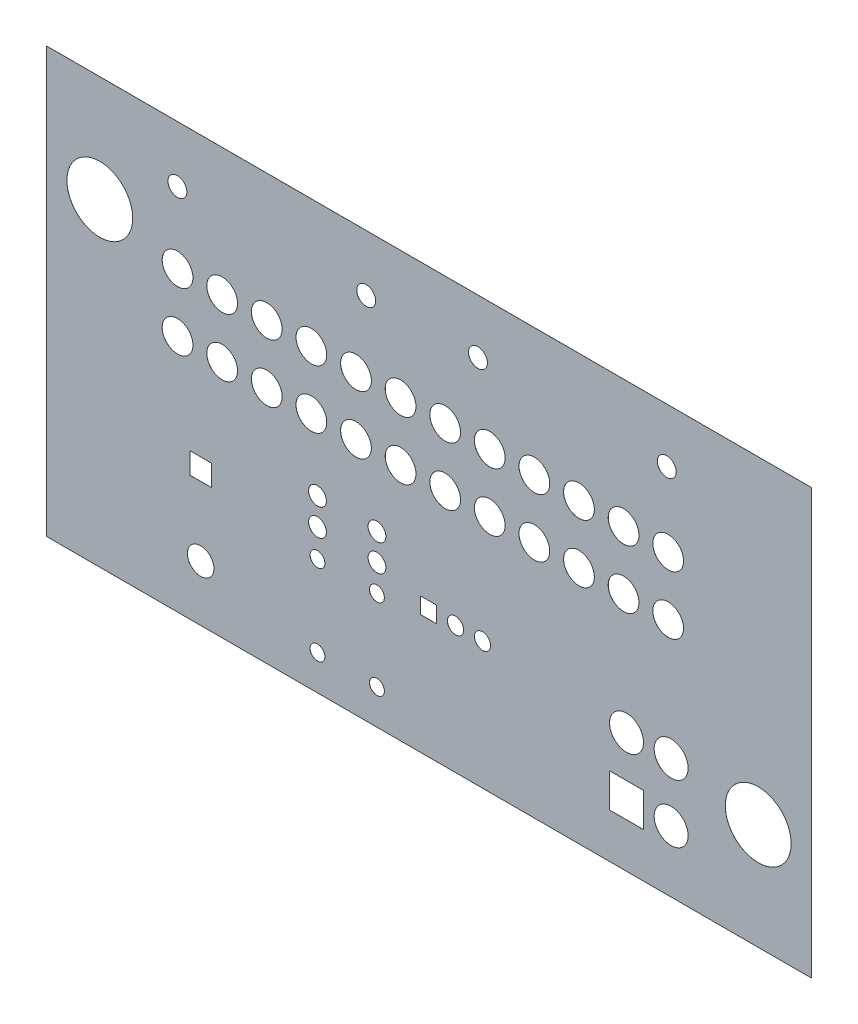
from build123d import *

# Parameters (mm, degrees)
SKETCH1_W           = 28346
SKETCH1_H           = 15748
SKETCH1_R           = 300
SKETCH1_R_2         = 570
SKETCH1_R_3         = 350
SKETCH1_R_4         = 275
SKETCH1_R_5         = 330
SKETCH1_R_6         = 492
SKETCH1_R_7         = 1220
SKETCH1_R_8         = 630
SKETCH1_W_2         = 600
SKETCH1_H_2         = 600
SKETCH1_W_3         = 786
SKETCH1_H_3         = 786
SKETCH1_W_4         = 1260
SKETCH1_H_4         = 1260
BOSS_EXTRUDE1_DEPTH = 1.6


with BuildPart() as part:
    # Sketch1 → Boss-Extrude1 (new body)
    with BuildSketch(Plane.XY):
        with Locations((53932, 38316)):
            Rectangle(SKETCH1_W, SKETCH1_H)
        with Locations((54917, 35166)):
            Circle(SKETCH1_R, mode=Mode.SUBTRACT)
        with Locations((55917, 35166)):
            Circle(SKETCH1_R, mode=Mode.SUBTRACT)
        with Locations((62799, 39296)):
            Circle(SKETCH1_R_2, mode=Mode.SUBTRACT)
        with Locations((61146, 39296)):
            Circle(SKETCH1_R_2, mode=Mode.SUBTRACT)
        with Locations((59492, 39296)):
            Circle(SKETCH1_R_2, mode=Mode.SUBTRACT)
        with Locations((57839, 39296)):
            Circle(SKETCH1_R_2, mode=Mode.SUBTRACT)
        with Locations((56185, 39296)):
            Circle(SKETCH1_R_2, mode=Mode.SUBTRACT)
        with Locations((54532, 39296)):
            Circle(SKETCH1_R_2, mode=Mode.SUBTRACT)
        with Locations((52879, 39296)):
            Circle(SKETCH1_R_2, mode=Mode.SUBTRACT)
        with Locations((51226, 39296)):
            Circle(SKETCH1_R_2, mode=Mode.SUBTRACT)
        with Locations((49572, 39296)):
            Circle(SKETCH1_R_2, mode=Mode.SUBTRACT)
        with Locations((47919, 39296)):
            Circle(SKETCH1_R_2, mode=Mode.SUBTRACT)
        with Locations((46265, 39296)):
            Circle(SKETCH1_R_2, mode=Mode.SUBTRACT)
        with Locations((44611, 39296)):
            Circle(SKETCH1_R_2, mode=Mode.SUBTRACT)
        with Locations((62799, 41461)):
            Circle(SKETCH1_R_2, mode=Mode.SUBTRACT)
        with Locations((61146, 41461)):
            Circle(SKETCH1_R_2, mode=Mode.SUBTRACT)
        with Locations((59492, 41461)):
            Circle(SKETCH1_R_2, mode=Mode.SUBTRACT)
        with Locations((57839, 41461)):
            Circle(SKETCH1_R_2, mode=Mode.SUBTRACT)
        with Locations((56185, 41461)):
            Circle(SKETCH1_R_2, mode=Mode.SUBTRACT)
        with Locations((54532, 41461)):
            Circle(SKETCH1_R_2, mode=Mode.SUBTRACT)
        with Locations((52879, 41461)):
            Circle(SKETCH1_R_2, mode=Mode.SUBTRACT)
        with Locations((51226, 41461)):
            Circle(SKETCH1_R_2, mode=Mode.SUBTRACT)
        with Locations((49572, 41461)):
            Circle(SKETCH1_R_2, mode=Mode.SUBTRACT)
        with Locations((47919, 41461)):
            Circle(SKETCH1_R_2, mode=Mode.SUBTRACT)
        with Locations((46265, 41461)):
            Circle(SKETCH1_R_2, mode=Mode.SUBTRACT)
        with Locations((44611, 41461)):
            Circle(SKETCH1_R_2, mode=Mode.SUBTRACT)
        with Locations((44605, 44103)):
            Circle(SKETCH1_R_3, mode=Mode.SUBTRACT)
        with Locations((51605, 44103)):
            Circle(SKETCH1_R_3, mode=Mode.SUBTRACT)
        with Locations((62747, 44182)):
            Circle(SKETCH1_R_3, mode=Mode.SUBTRACT)
        with Locations((55747, 44182)):
            Circle(SKETCH1_R_3, mode=Mode.SUBTRACT)
        with Locations((52003, 34737)):
            Circle(SKETCH1_R_4, mode=Mode.SUBTRACT)
        with Locations((52003, 31737)):
            Circle(SKETCH1_R_4, mode=Mode.SUBTRACT)
        with Locations((49798, 34737)):
            Circle(SKETCH1_R_4, mode=Mode.SUBTRACT)
        with Locations((49798, 31737)):
            Circle(SKETCH1_R_4, mode=Mode.SUBTRACT)
        with Locations((52003, 36729)):
            Circle(SKETCH1_R_5, mode=Mode.SUBTRACT)
        with Locations((52003, 35729)):
            Circle(SKETCH1_R_5, mode=Mode.SUBTRACT)
        with Locations((49798, 36768)):
            Circle(SKETCH1_R_5, mode=Mode.SUBTRACT)
        with Locations((49798, 35768)):
            Circle(SKETCH1_R_5, mode=Mode.SUBTRACT)
        with Locations((45468, 32509)):
            Circle(SKETCH1_R_6, mode=Mode.SUBTRACT)
        with Locations((41728, 42253)):
            Circle(SKETCH1_R_7, mode=Mode.SUBTRACT)
        with Locations((66137, 34379)):
            Circle(SKETCH1_R_7, mode=Mode.SUBTRACT)
        with Locations((62909, 32725)):
            Circle(SKETCH1_R_8, mode=Mode.SUBTRACT)
        with Locations((61255, 34890)):
            Circle(SKETCH1_R_8, mode=Mode.SUBTRACT)
        with Locations((62909, 34890)):
            Circle(SKETCH1_R_8, mode=Mode.SUBTRACT)
        with Locations((53917, 35166)):
            Rectangle(SKETCH1_W_2, SKETCH1_H_2, mode=Mode.SUBTRACT)
        with Locations((45468, 35461)):
            Rectangle(SKETCH1_W_3, SKETCH1_H_3, mode=Mode.SUBTRACT)
        with Locations((61255, 32725)):
            Rectangle(SKETCH1_W_4, SKETCH1_H_4, mode=Mode.SUBTRACT)
    extrude(amount=BOSS_EXTRUDE1_DEPTH)


solid = part.part
